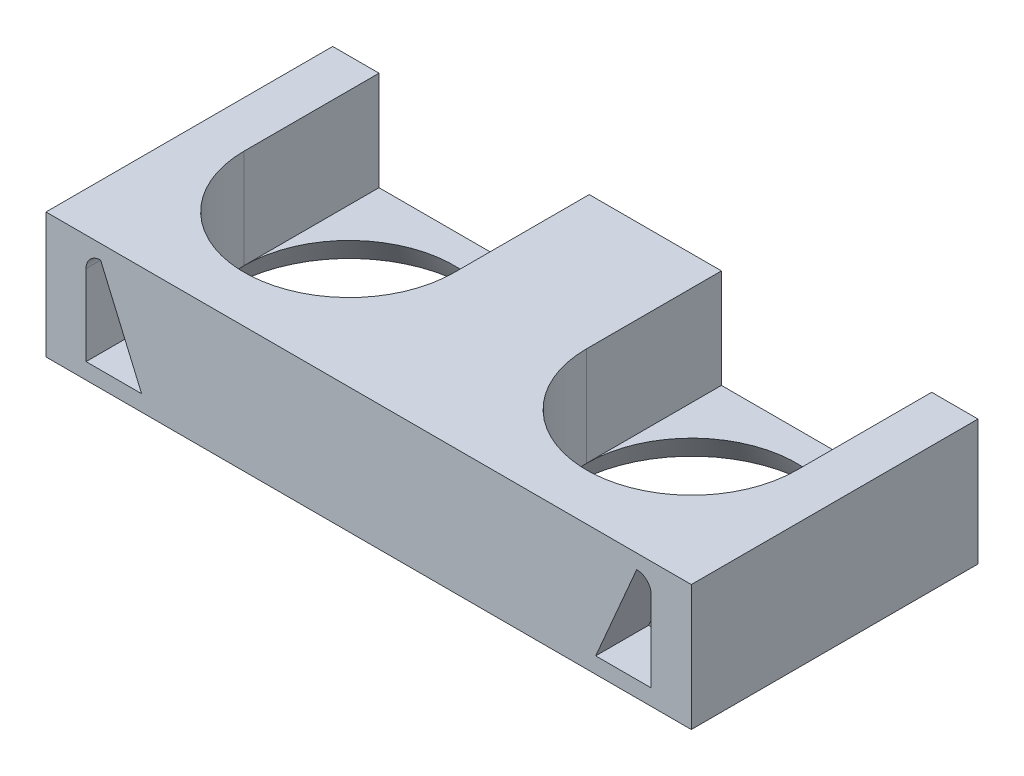
from build123d import *

# Parameters (mm, degrees)
SALIENTE_EXTRUIR1_DEPTH = 7.5
CROQUIS3_W              = 48.808095268
CROQUIS3_H              = 21.684781413
SALIENTE_EXTRUIR2_DEPTH = 2
CROQUIS4_R              = 7.95
CORTAR_EXTRUIR1_DEPTH   = 3
CORTAR_EXTRUIR1_TAPER   = -30
CORTAR_EXTRUIR2_DEPTH   = 4


with BuildPart() as part:
    # Croquis2 → Saliente-Extruir1 (new body)
    with BuildSketch(Plane(origin=(0, -4.9, 0), x_dir=(-1, 0, 0), z_dir=(0, -1, 0))):
        with BuildLine():
            Line((-5, 20.4), (5, 20.4))
            Line((5, 20.4), (5, 10.2))
            ThreePointArc((5, 10.2), (12.95, 2.25), (20.9, 10.2))
            Line((20.9, 10.2), (20.9, 20.4))
            Line((20.9, 20.4), (24.404047634, 20.4))
            Line((24.404047634, 20.4), (24.404047634, -1.284781413))
            Line((24.404047634, -1.284781413), (-24.404047634, -1.284781413))
            Line((-24.404047634, -1.284781413), (-24.404047634, 20.4))
            Line((-24.404047634, 20.4), (-20.9, 20.4))
            Line((-20.9, 20.4), (-20.9, 10.2))
            ThreePointArc((-20.9, 10.2), (-12.95, 2.25), (-5, 10.2))
            Line((-5, 10.2), (-5, 20.4))
        make_face()
    extrude(amount=SALIENTE_EXTRUIR1_DEPTH)

    # Croquis3 → Saliente-Extruir2 (add)
    with BuildSketch(Plane.XZ.offset(12.4)):
        with Locations((0, -9.557609294)):
            Rectangle(CROQUIS3_W, CROQUIS3_H)
    extrude(amount=SALIENTE_EXTRUIR2_DEPTH)

    # Croquis4 → Cortar-Extruir1 (cut)
    with BuildSketch(Plane.XZ.offset(12.4)):
        with Locations((-12.95, -10.2)):
            Circle(CROQUIS4_R)
        with Locations((12.95, -10.2)):
            Circle(CROQUIS4_R)
    extrude(amount=CORTAR_EXTRUIR1_DEPTH, taper=CORTAR_EXTRUIR1_TAPER, mode=Mode.SUBTRACT)

    # Croquis7 → Cortar-Extruir2 (cut)
    with BuildSketch(Plane.XY.offset(1.284781413)):
        with BuildLine():
            Line((-21.373206473, -7.088443063), (-21.373206473, -13.188443063))
            Line((-21.373206473, -13.188443063), (-17.173206473, -13.188443063))
            Line((-17.173206473, -13.188443063), (-20.273206473, -5.988443063))
            ThreePointArc((-20.273206473, -5.988443063), (-21.051023932, -6.310625604), (-21.373206473, -7.088443063))
        make_face()
        with BuildLine():
            Line((21.373206473, -13.188443063), (17.173206473, -13.188443063))
            Line((17.173206473, -13.188443063), (20.273206473, -5.988443063))
            ThreePointArc((20.273206473, -5.988443063), (21.051023932, -6.310625604), (21.373206473, -7.088443063))
            Line((21.373206473, -7.088443063), (21.373206473, -13.188443063))
        make_face()
    extrude(amount=-CORTAR_EXTRUIR2_DEPTH, mode=Mode.SUBTRACT)


solid = part.part
